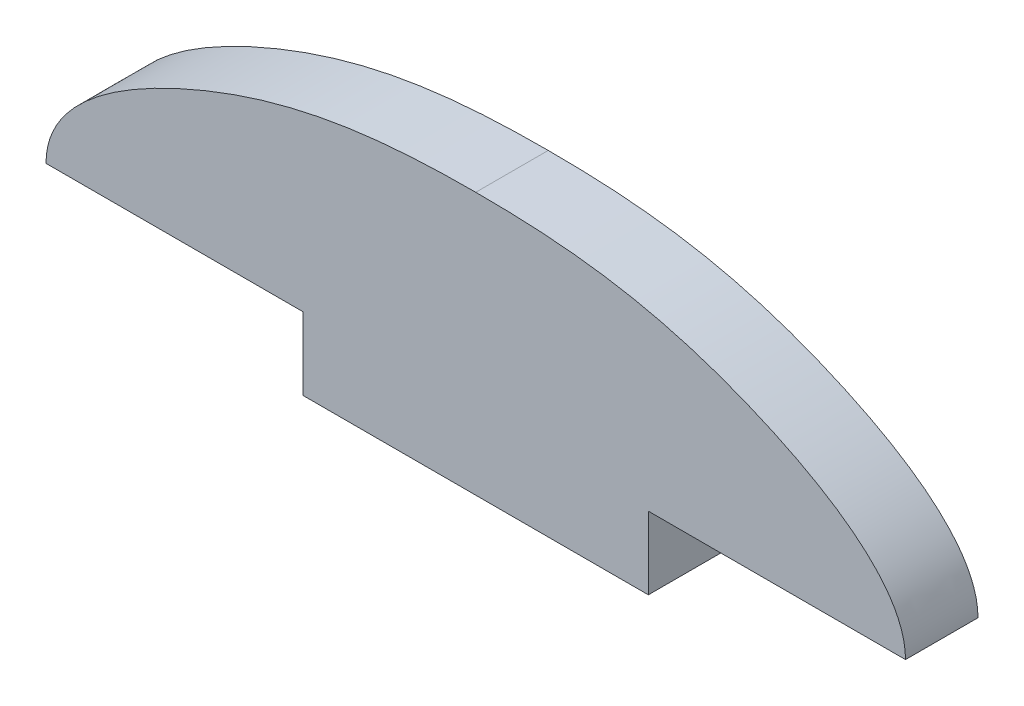
from build123d import *

# Parameters (mm, degrees)
SKETCH1_W           = 25.4
SKETCH1_H           = 5.334
BOSS_EXTRUDE1_DEPTH = 5.334


with BuildPart() as part:
    # Sketch1 → Boss-Extrude1 (new body)
    with BuildSketch(Plane.XY):
        with BuildLine():
            Line((-31.623, 41.4528), (31.623, 41.4528))
            add(Edge.make_bspline(
                [(31.623, 41.4528), (31.623, 45.877417285), (17.945030391, 54.271973515), (6.990328103, 55.4228), (0, 55.4228)],
                knots=[0, 0, 0, 0, 0.410117749, 1, 1, 1, 1], degree=3))
            add(Edge.make_bspline(
                [(-31.623, 41.4528), (-31.623, 45.877417285), (-17.945030391, 54.271973515), (-6.990328103, 55.4228), (0, 55.4228)],
                knots=[0, 0, 0, 0, 0.410117749, 1, 1, 1, 1], degree=3))
        make_face()
        with Locations((0, 38.7858)):
            Rectangle(SKETCH1_W, SKETCH1_H)
    extrude(amount=BOSS_EXTRUDE1_DEPTH)


solid = part.part
